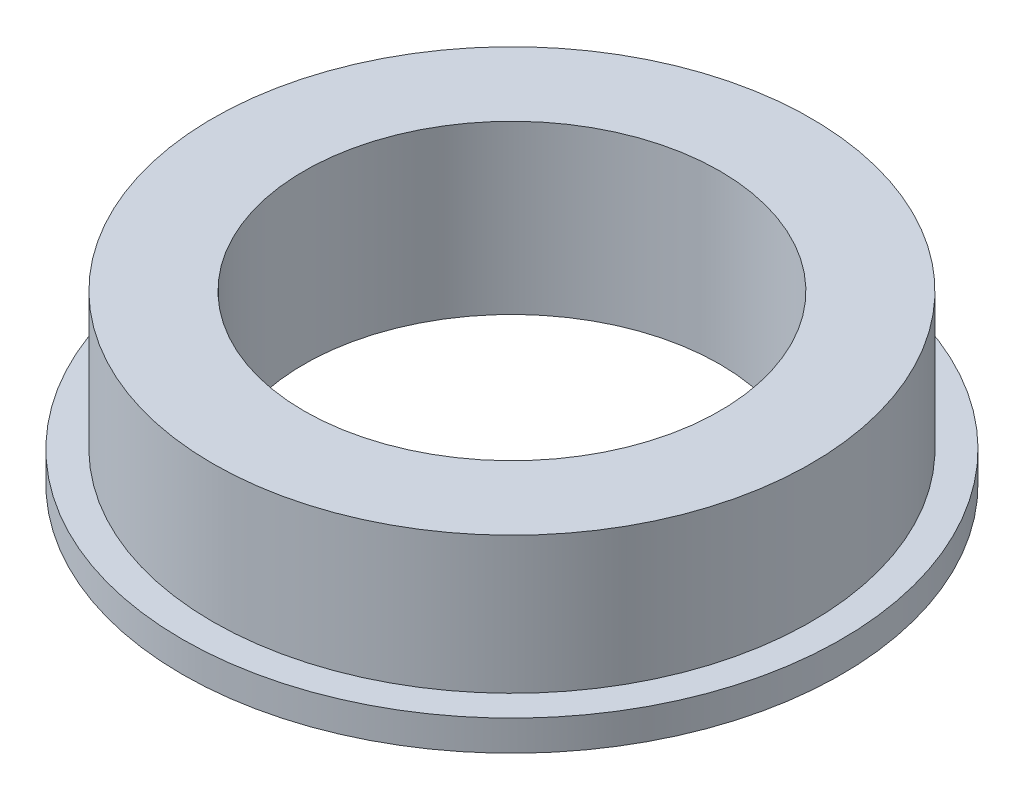
from build123d import *


with BuildPart() as part:
    # Sketch1 → Revolve1 (revolve)
    with BuildSketch(Plane.XY):
        Polygon((4.1, 0.1), (4.1, 3.4), (5.9, 3.4), (5.9, 0.7), (6.5, 0.7), (6.5, 0.1), align=None)
    revolve(axis=Axis((0, 2.634680759, 0), (0, -1, 0)))


solid = part.part
